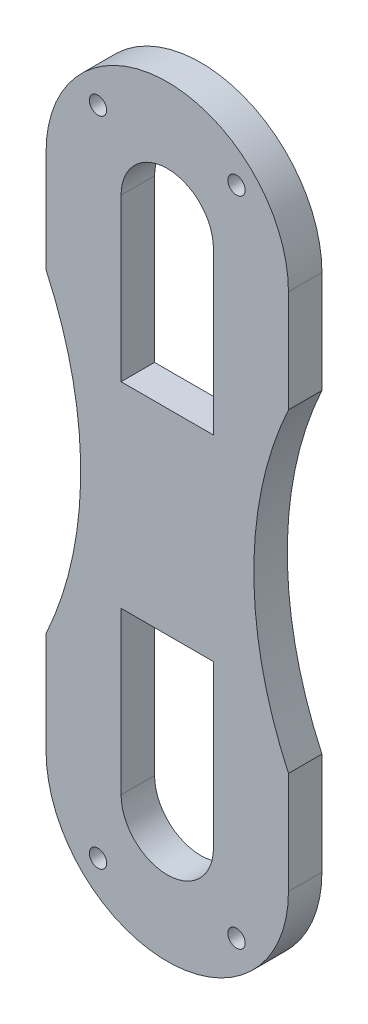
from build123d import *

# Parameters (mm, degrees)
SKETCH_1_R      = 0.75
EXTRUDE_1_DEPTH = 2.9


with BuildPart() as part:
    # 草图1 → 凸台-拉伸1 (new body)
    with BuildSketch(Plane.XY):
        with BuildLine():
            Line((-10.5, 22.5), (-10.5, 13.638181697))
            ThreePointArc((-10.5, 13.638181697), (-7.5, 0), (-10.5, -13.638181697))
            Line((-10.5, -13.638181697), (-10.5, -22.5))
            ThreePointArc((-10.5, -22.5), (0, -33), (10.5, -22.5))
            Line((10.5, -22.5), (10.5, -13.638181697))
            ThreePointArc((10.5, -13.638181697), (7.5, 0), (10.5, 13.638181697))
            Line((10.5, 13.638181697), (10.5, 22.5))
            ThreePointArc((10.5, 22.5), (0, 33), (-10.5, 22.5))
        make_face()
        with Locations((6, 28.25)):
            Circle(SKETCH_1_R, mode=Mode.SUBTRACT)
        with Locations((-6, 28.25)):
            Circle(SKETCH_1_R, mode=Mode.SUBTRACT)
        with Locations((6, -28.25)):
            Circle(SKETCH_1_R, mode=Mode.SUBTRACT)
        with Locations((-6, -28.25)):
            Circle(SKETCH_1_R, mode=Mode.SUBTRACT)
        with BuildLine():
            ThreePointArc((4, 22.500000371), (-3.71e-07, 26.5), (-4, 22.499999629))
            Line((-4, 22.499999629), (-4, 8.5))
            Line((-4, 8.5), (4, 8.5))
            Line((4, 8.5), (4, 22.500000371))
        make_face(mode=Mode.SUBTRACT)
        with BuildLine():
            Line((4, -22.500000371), (4, -8.5))
            Line((4, -8.5), (-4, -8.5))
            Line((-4, -8.5), (-4, -22.499999629))
            ThreePointArc((-4, -22.499999629), (-3.71e-07, -26.5), (4, -22.500000371))
        make_face(mode=Mode.SUBTRACT)
    extrude(amount=EXTRUDE_1_DEPTH)


solid = part.part
